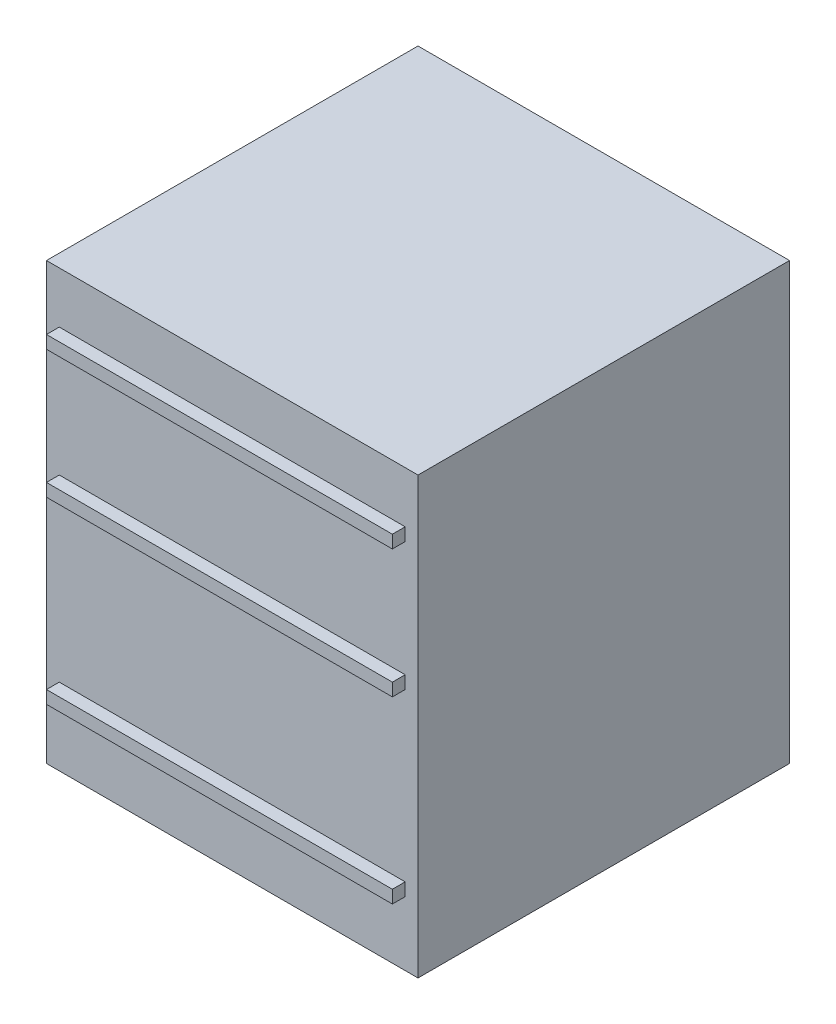
from build123d import *

# Parameters (mm, degrees)
SKETCH1_W           = 736.6
SKETCH1_H           = 736.6
BOSS_EXTRUDE1_DEPTH = 863.6
SKETCH2_W           = 685.8
SKETCH2_H           = 25.4
BOSS_EXTRUDE2_DEPTH = 25.4


with BuildPart() as part:
    # Sketch1 → Boss-Extrude1 (new body)
    with BuildSketch(Plane(origin=(0, 0, 0), x_dir=(1, 0, 0), z_dir=(0, 1, 0))):
        Rectangle(SKETCH1_W, SKETCH1_H)
    extrude(amount=BOSS_EXTRUDE1_DEPTH)

    # Sketch2 → Boss-Extrude2 (add)
    with BuildSketch(Plane.XY.offset(368.3)):
        with Locations((0, 749.3)):
            Rectangle(SKETCH2_W, SKETCH2_H)
        with Locations((0, 495.3)):
            Rectangle(SKETCH2_W, SKETCH2_H)
        with Locations((0, 139.7)):
            Rectangle(SKETCH2_W, SKETCH2_H)
    extrude(amount=BOSS_EXTRUDE2_DEPTH)


solid = part.part
